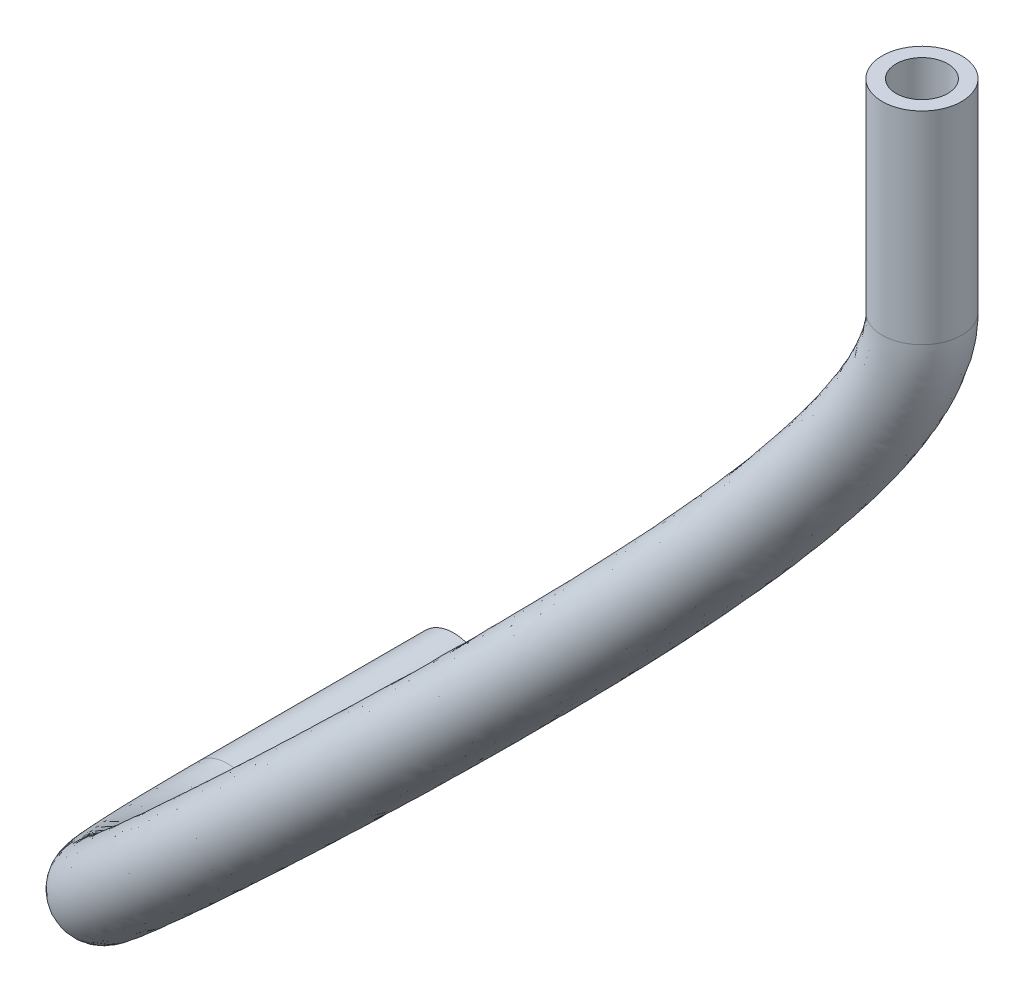
from build123d import *

# Parameters (mm, degrees)
SKETCH1_R   = 2
SKETCH1_R_2 = 1.3


with BuildPart() as part:
    # Sweep1: sweep along a curve in space
    with BuildLine() as sweep1_path:
        Line((-150.085279081, -109.482256564, -25.525), (-150.085279081, -119.682256564, -25.525))
        add(Edge.make_bspline(
            [(-150.085279081, -119.682256564, -25.525), (-150.085279081, -124.369613152, -25.525), (-171.159160942, -147.727370667, -24.664949167), (-209.245695812, -183.033658174, -34.126800908), (-209.245695812, -183.033658174, -49.6875)],
            knots=[0, 0, 0, 0, 0.428585934, 1, 1, 1, 1], degree=3))
        Line((-209.245695812, -183.033658174, -61.0875), (-209.245695812, -183.033658174, -49.6875))
    # Sketch1 → Sweep1 (sweep)
    with BuildSketch(Plane.XY.offset(-51.4875)):
        with Locations((-209.245695812, -183.033658174)):
            Circle(SKETCH1_R)
        with Locations((-209.245695812, -183.033658174)):
            Circle(SKETCH1_R_2, mode=Mode.SUBTRACT)
    sweep(path=sweep1_path.line)


solid = part.part
